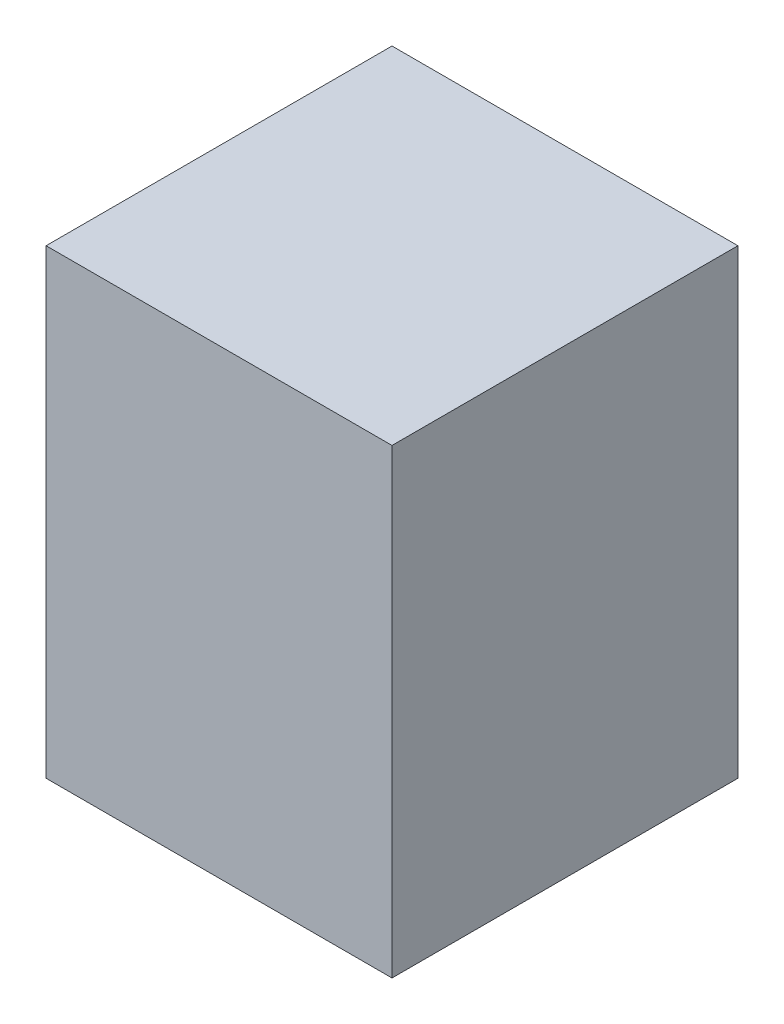
from build123d import *

# Parameters (mm, degrees)
SKETCH1_W           = 304.8
SKETCH1_H           = 304.8
BOSS_EXTRUDE1_DEPTH = 406.4


with BuildPart() as part:
    # Sketch1 → Boss-Extrude1 (new body)
    with BuildSketch(Plane(origin=(0, 0, 0), x_dir=(1, 0, 0), z_dir=(0, 1, 0))):
        with Locations((152.4, 152.4)):
            Rectangle(SKETCH1_W, SKETCH1_H)
    extrude(amount=BOSS_EXTRUDE1_DEPTH)


solid = part.part
